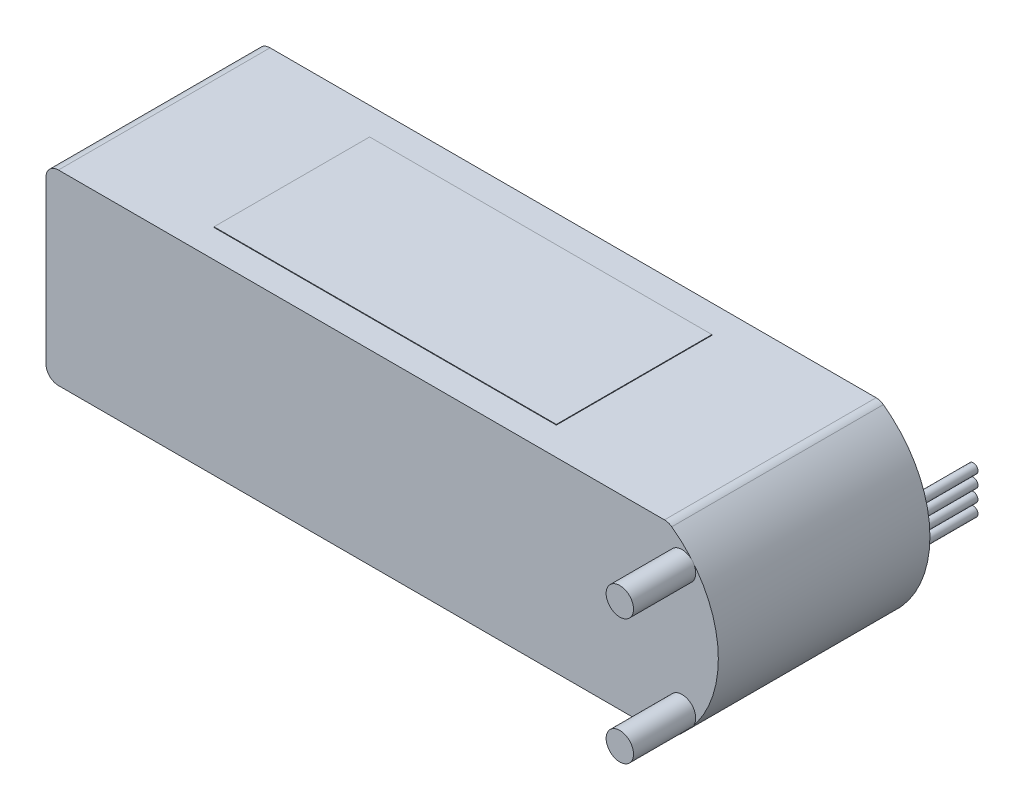
from build123d import *

# Parameters (mm, degrees)
EXTRUDE_1_DEPTH   = 17
SKETCH_2_R        = 2.2
EXTRUDE_2_DEPTH   = 10
EXTRUDE_2_2_DEPTH = 10
SKETCH_3_R        = 0.75
EXTRUDE_3_DEPTH   = 10
EXTRUDE_3_2_DEPTH = 10
EXTRUDE_3_3_DEPTH = 10
EXTRUDE_3_4_DEPTH = 10
SKETCH_5_W        = 55
SKETCH_5_H        = 25
EXTRUDE_4_DEPTH   = 0.1
FILLET_1_R        = 2


with BuildPart() as part:
    # 草图1 → 凸台-拉伸1 (new body, symmetric)
    with BuildSketch(Plane.XY):
        with BuildLine():
            Line((-50, 15), (50, 15))
            ThreePointArc((50, 15), (58.027756377, 0), (50, -15))
            Line((50, -15), (-50, -15))
            Line((-50, -15), (-50, 15))
        make_face()
    extrude(amount=EXTRUDE_1_DEPTH, both=True)

    # 草图5 → 凸台-拉伸4 (add)
    with BuildSketch(Plane(origin=(0, 15, 0), x_dir=(1, 0, 0), z_dir=(0, 1, 0))):
        Rectangle(SKETCH_5_W, SKETCH_5_H)
    extrude(amount=EXTRUDE_4_DEPTH)

    # 圆角1
    fillet_1_edges = [part.edges().sort_by_distance(p)[0] for p in [
        (50, -15, 0),
        (-50, -15, 0),
        (-50, 15, 0),
        (50, 15, 0),
    ]]
    fillet(fillet_1_edges, radius=FILLET_1_R)


with BuildPart() as body_2:
    # 草图2 → 凸台-拉伸2 (new body)
    with BuildSketch(Plane.XY.offset(17)):
        with Locations((52.2, 10.083544612)):
            Circle(SKETCH_2_R)
    extrude(amount=EXTRUDE_2_DEPTH)


with BuildPart() as body_3:
    # 草图2 → Extrude 2 2 (new body)
    with BuildSketch(Plane.XY.offset(17)):
        with Locations((52.2, -10.083544612)):
            Circle(SKETCH_2_R)
    extrude(amount=EXTRUDE_2_2_DEPTH)


with BuildPart() as body_4:
    # 草图3 → 凸台-拉伸3 (new body)
    with BuildSketch(Plane(origin=(0, 0, -17), x_dir=(-1, 0, 0), z_dir=(0, 0, -1))):
        with Locations((-55, 3)):
            Circle(SKETCH_3_R)
    extrude(amount=EXTRUDE_3_DEPTH)


with BuildPart() as body_5:
    # 草图3 → Extrude 3 2 (new body)
    with BuildSketch(Plane(origin=(0, 0, -17), x_dir=(-1, 0, 0), z_dir=(0, 0, -1))):
        with Locations((-55, 1)):
            Circle(SKETCH_3_R)
    extrude(amount=EXTRUDE_3_2_DEPTH)


with BuildPart() as body_6:
    # 草图3 → Extrude 3 3 (new body)
    with BuildSketch(Plane(origin=(0, 0, -17), x_dir=(-1, 0, 0), z_dir=(0, 0, -1))):
        with Locations((-55, -1)):
            Circle(SKETCH_3_R)
    extrude(amount=EXTRUDE_3_3_DEPTH)


with BuildPart() as body_7:
    # 草图3 → Extrude 3 4 (new body)
    with BuildSketch(Plane(origin=(0, 0, -17), x_dir=(-1, 0, 0), z_dir=(0, 0, -1))):
        with Locations((-55, -3)):
            Circle(SKETCH_3_R)
    extrude(amount=EXTRUDE_3_4_DEPTH)


solid = Compound([part.part, body_2.part, body_3.part, body_4.part, body_5.part, body_6.part, body_7.part])
